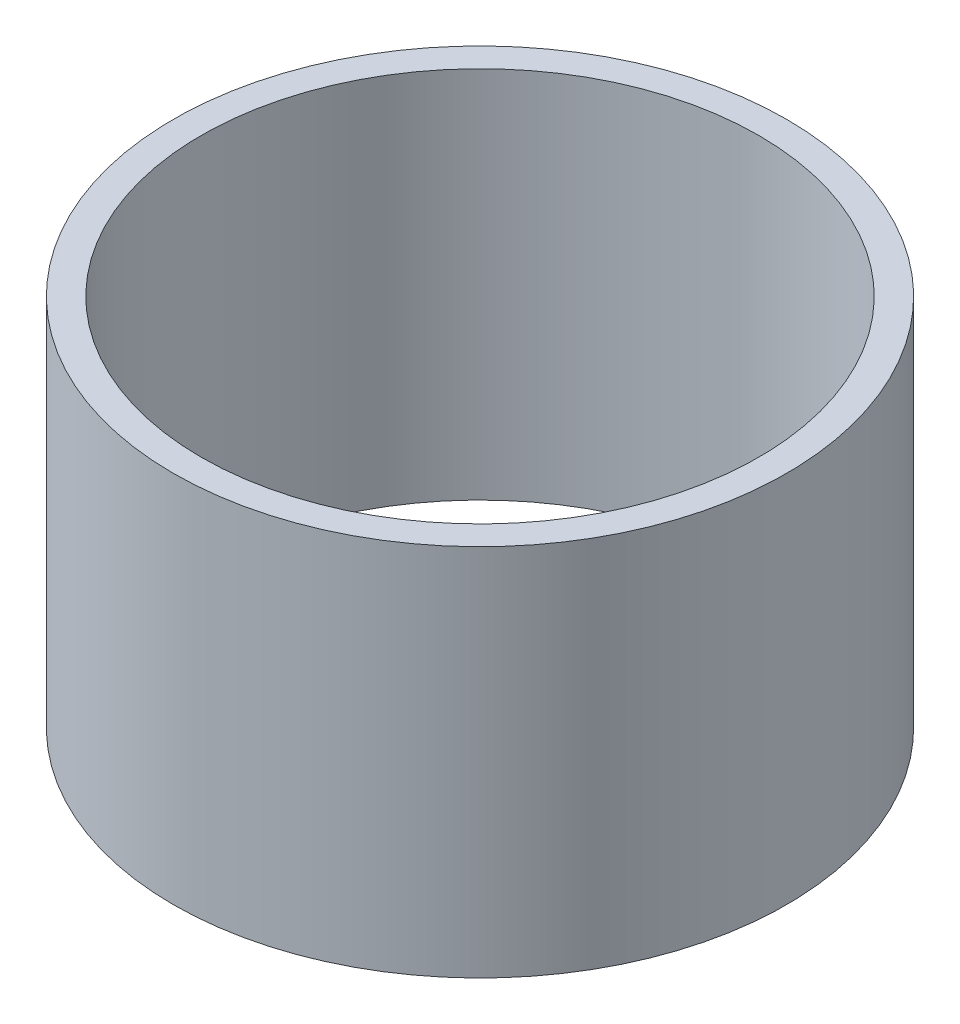
from build123d import *

# Parameters (mm, degrees)
SKETCH1_R           = 55
SKETCH1_R_2         = 50
BOSS_EXTRUDE1_DEPTH = 67


with BuildPart() as part:
    # Sketch1 → Boss-Extrude1 (new body)
    with BuildSketch(Plane(origin=(0, 0, 0), x_dir=(1, 0, 0), z_dir=(0, 1, 0))):
        Circle(SKETCH1_R)
        Circle(SKETCH1_R_2, mode=Mode.SUBTRACT)
    extrude(amount=BOSS_EXTRUDE1_DEPTH)


solid = part.part
